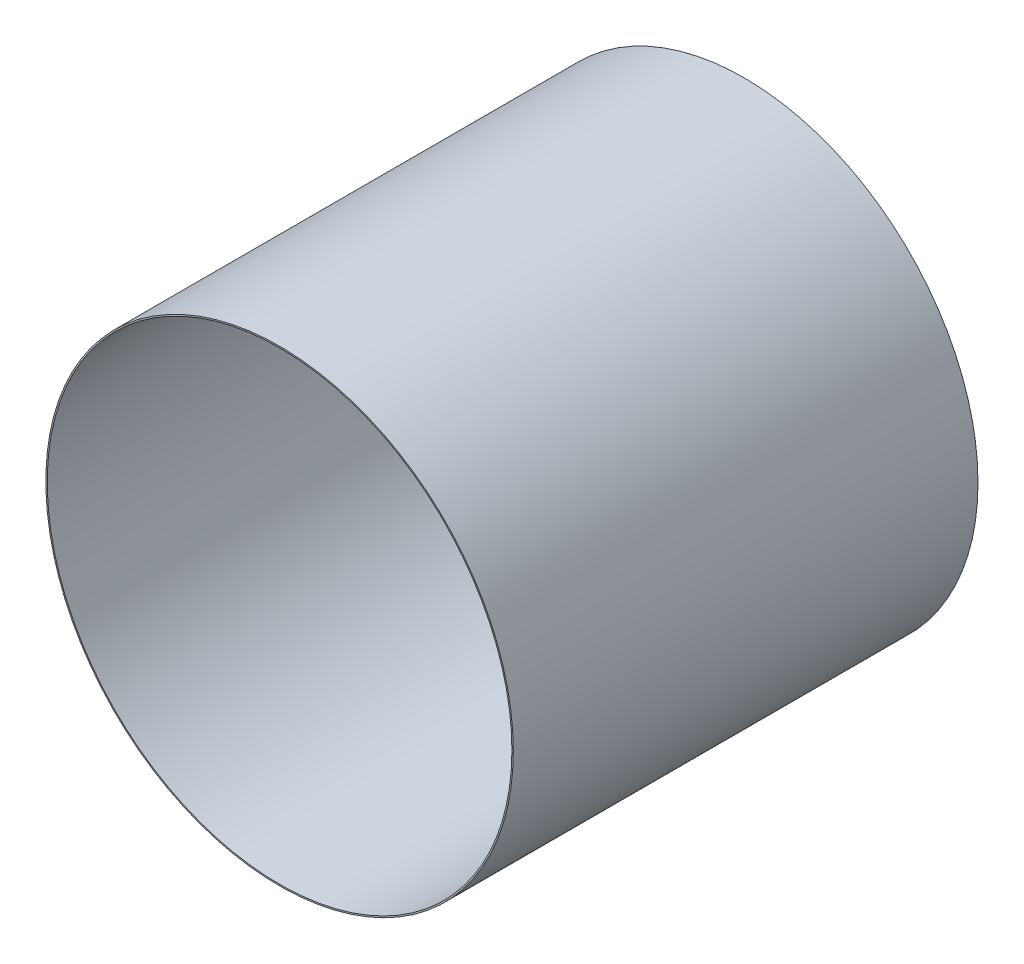
from build123d import *

# Parameters (mm, degrees)
SKETCH1_R           = 38.32733
BOSS_EXTRUDE1_DEPTH = 76.2
SKETCH2_R           = 38.1
CUT_EXTRUDE1_DEPTH  = 76.2


with BuildPart() as part:
    # Sketch1 → Boss-Extrude1 (new body)
    with BuildSketch(Plane.XY):
        Circle(SKETCH1_R)
    extrude(amount=-BOSS_EXTRUDE1_DEPTH)

    # Sketch2 → Cut-Extrude1 (cut)
    with BuildSketch(Plane.XY):
        Circle(SKETCH2_R)
    extrude(amount=-CUT_EXTRUDE1_DEPTH, mode=Mode.SUBTRACT)


solid = part.part
